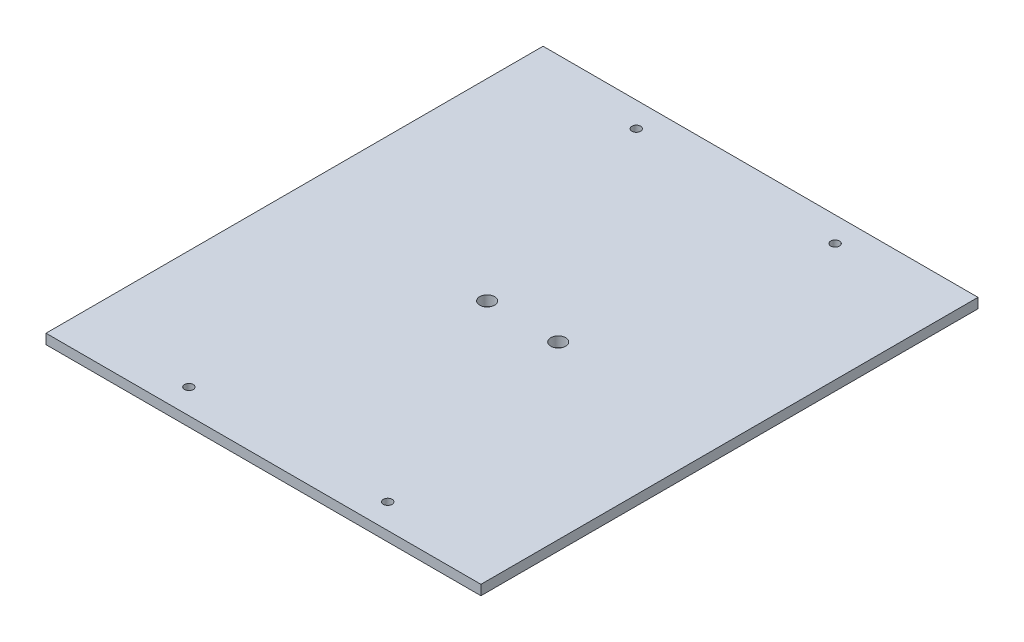
from build123d import *

# Parameters (mm, degrees)
SKETCH1_W             = 222.25
SKETCH1_H             = 254
BOSS_EXTRUDE1_DEPTH   = 5.08
SKETCH2_R             = 3.81
CUT_EXTRUDE2_DEPTH    = 6.08
F_8_CLEARANCE_HOLE1_D = 4.4958


with BuildPart() as part:
    # Sketch1 → Boss-Extrude1 (new body)
    with BuildSketch(Plane(origin=(0, 0, 0), x_dir=(1, 0, 0), z_dir=(0, 1, 0))):
        Rectangle(SKETCH1_W, SKETCH1_H)
    extrude(amount=BOSS_EXTRUDE1_DEPTH)

    # Sketch2 → Cut-Extrude2 (cut, through all)
    with BuildSketch(Plane(origin=(0, 0, 0), x_dir=(1, 0, 0), z_dir=(0, 1, 0))):
        with Locations((-12.7, 0)):
            Circle(SKETCH2_R)
        with Locations((23.622, 0)):
            Circle(SKETCH2_R)
    extrude(amount=CUT_EXTRUDE2_DEPTH, mode=Mode.SUBTRACT)

    # #8 Clearance Hole1 (through all)
    with Locations(Plane(origin=(0, 0, 0), x_dir=(-1, 0, 0), z_dir=(0, -1, 0))):
        with Locations((50.8, -114.3), (-50.8, -114.3), (-50.8, 114.3), (50.8, 114.3)):
            Hole(F_8_CLEARANCE_HOLE1_D / 2)


solid = part.part
